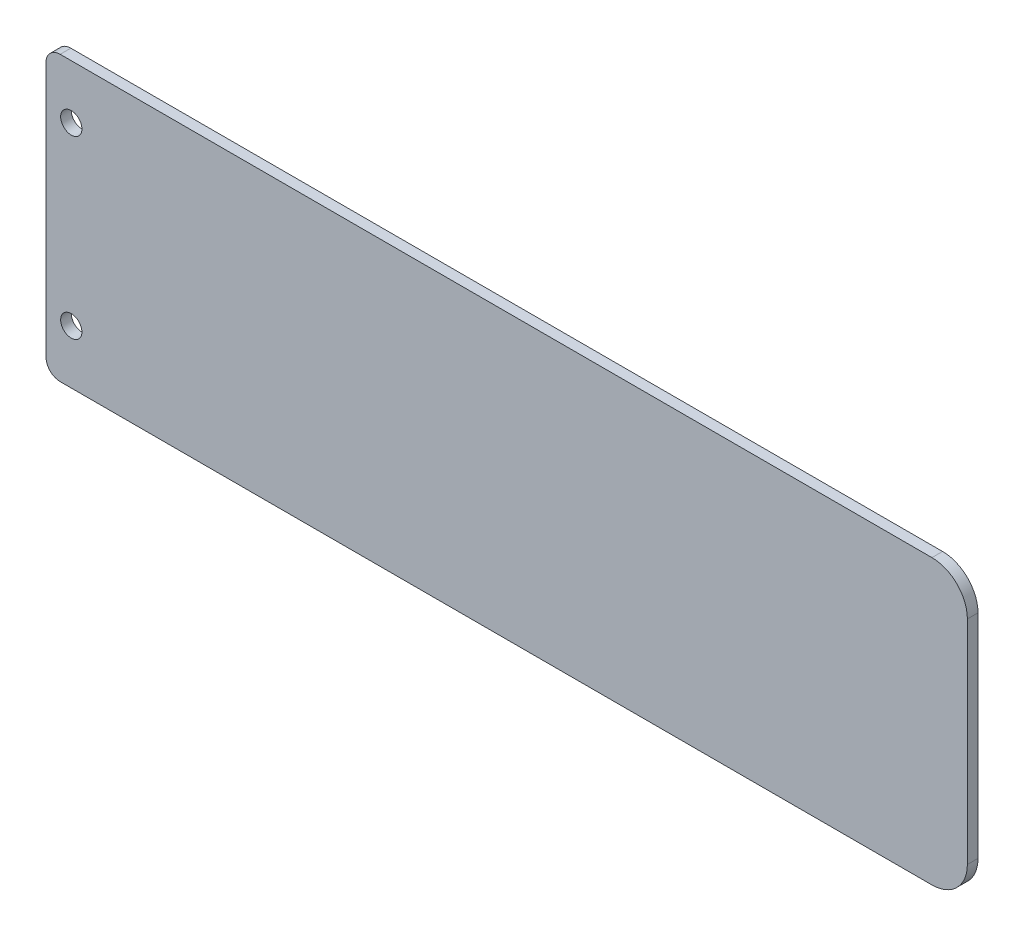
from build123d import *

# Parameters (mm, degrees)
ESQUISSE1_W             = 260
ESQUISSE1_H             = 80
BOSS_EXTRU_1_DEPTH      = 3
CONG_1_R                = 10
ESQUISSE3_R             = 3
ENL_V_MAT_EXTRU_1_DEPTH = 10
CONG_2_R                = 4


with BuildPart() as part:
    # Esquisse1 → Boss.-Extru.1 (new body)
    with BuildSketch(Plane.XY):
        with Locations((130, 40)):
            Rectangle(ESQUISSE1_W, ESQUISSE1_H)
    extrude(amount=BOSS_EXTRU_1_DEPTH)

    # Congé1
    cong_1_edges = [part.edges().sort_by_distance(p)[0] for p in [
        (260, 80, 1.5),
        (260, 0, 1.5),
    ]]
    fillet(cong_1_edges, radius=CONG_1_R)

    # Esquisse3 → Enlèv. mat.-Extru.1 (cut)
    with BuildSketch(Plane.XY.offset(3)):
        with Locations((7.133710771, 64.818289226)):
            Circle(ESQUISSE3_R)
        with Locations((7.133710771, 15.193861177)):
            Circle(ESQUISSE3_R)
    extrude(amount=-ENL_V_MAT_EXTRU_1_DEPTH, mode=Mode.SUBTRACT)

    # Congé2
    cong_2_edges = [part.edges().sort_by_distance(p)[0] for p in [
        (0, 80, 1.5),
        (0, 0, 1.5),
    ]]
    fillet(cong_2_edges, radius=CONG_2_R)


solid = part.part
